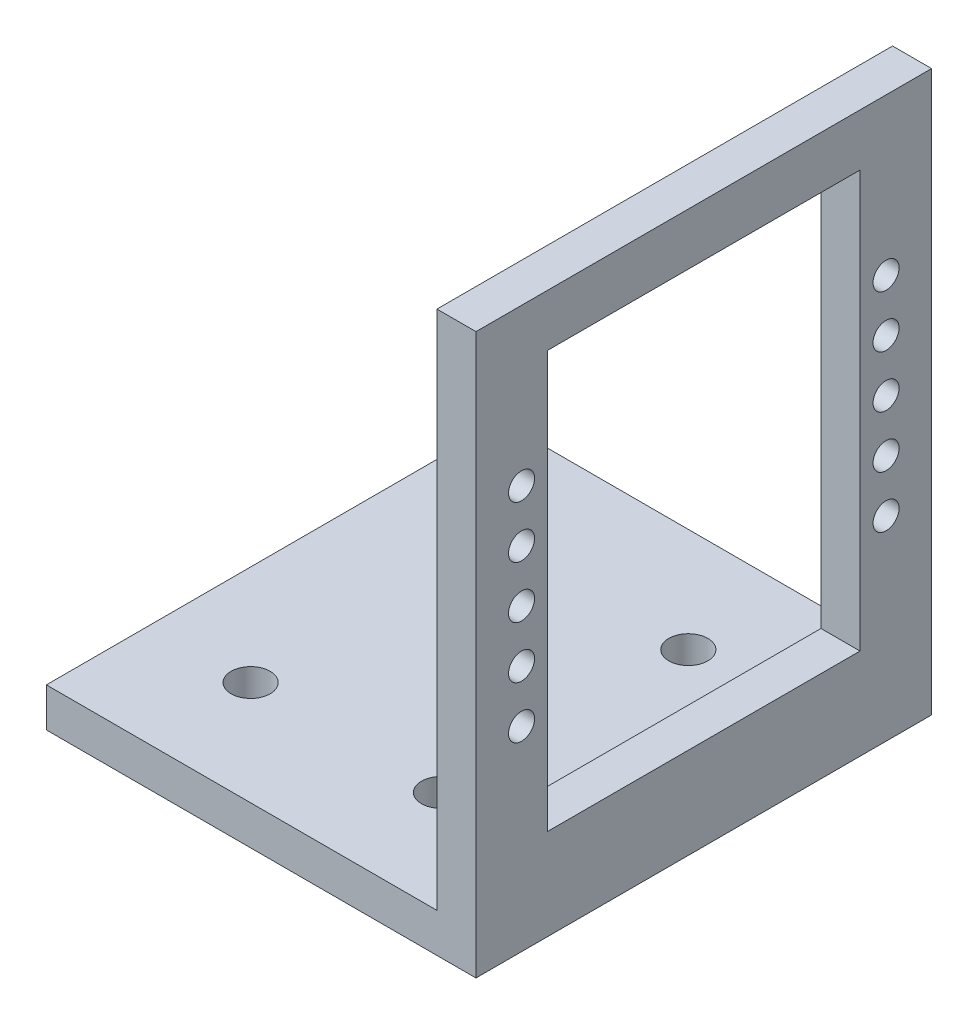
from build123d import *

# Parameters (mm, degrees)
EXTRUDE_1_DEPTH     = 35
SKETCH_2_W          = 24
SKETCH_2_H          = 32
SKETCH_2_R          = 1
CUT_EXTRUDE_1_DEPTH = 4
SKETCH_3_R          = 1.5
CUT_EXTRUDE_2_DEPTH = 4


with BuildPart() as part:
    # 草图1 → 凸台-拉伸1 (new body)
    with BuildSketch(Plane.XY):
        Polygon((-33, 0), (0, 0), (0, 43), (-3, 43), (-3, 3), (-33, 3), align=None)
    extrude(amount=EXTRUDE_1_DEPTH)

    # 草图2 → 切除-拉伸1 (cut, through all)
    with BuildSketch(Plane.ZY.offset(3)):
        with Locations((17.5, 23)):
            Rectangle(SKETCH_2_W, SKETCH_2_H)
        with Locations((3.5, 31)):
            Circle(SKETCH_2_R)
        with Locations((3.5, 27)):
            Circle(SKETCH_2_R)
        with Locations((3.5, 23)):
            Circle(SKETCH_2_R)
        with Locations((3.5, 19)):
            Circle(SKETCH_2_R)
        with Locations((3.5, 15)):
            Circle(SKETCH_2_R)
        with Locations((31.5, 15)):
            Circle(SKETCH_2_R)
        with Locations((31.5, 19)):
            Circle(SKETCH_2_R)
        with Locations((31.5, 23)):
            Circle(SKETCH_2_R)
        with Locations((31.5, 27)):
            Circle(SKETCH_2_R)
        with Locations((31.5, 31)):
            Circle(SKETCH_2_R)
    extrude(amount=-CUT_EXTRUDE_1_DEPTH, mode=Mode.SUBTRACT)

    # 草图3 → 切除-拉伸2 (cut, through all)
    with BuildSketch(Plane(origin=(0, 3, 0), x_dir=(1, 0, 0), z_dir=(0, 1, 0))):
        with Locations((-25.310950673, -8)):
            Circle(SKETCH_3_R)
        with Locations((-10.689049327, -8)):
            Circle(SKETCH_3_R)
        with Locations((-10.689049327, -27)):
            Circle(SKETCH_3_R)
        with Locations((-25.310950673, -27)):
            Circle(SKETCH_3_R)
    extrude(amount=-CUT_EXTRUDE_2_DEPTH, mode=Mode.SUBTRACT)


solid = part.part
